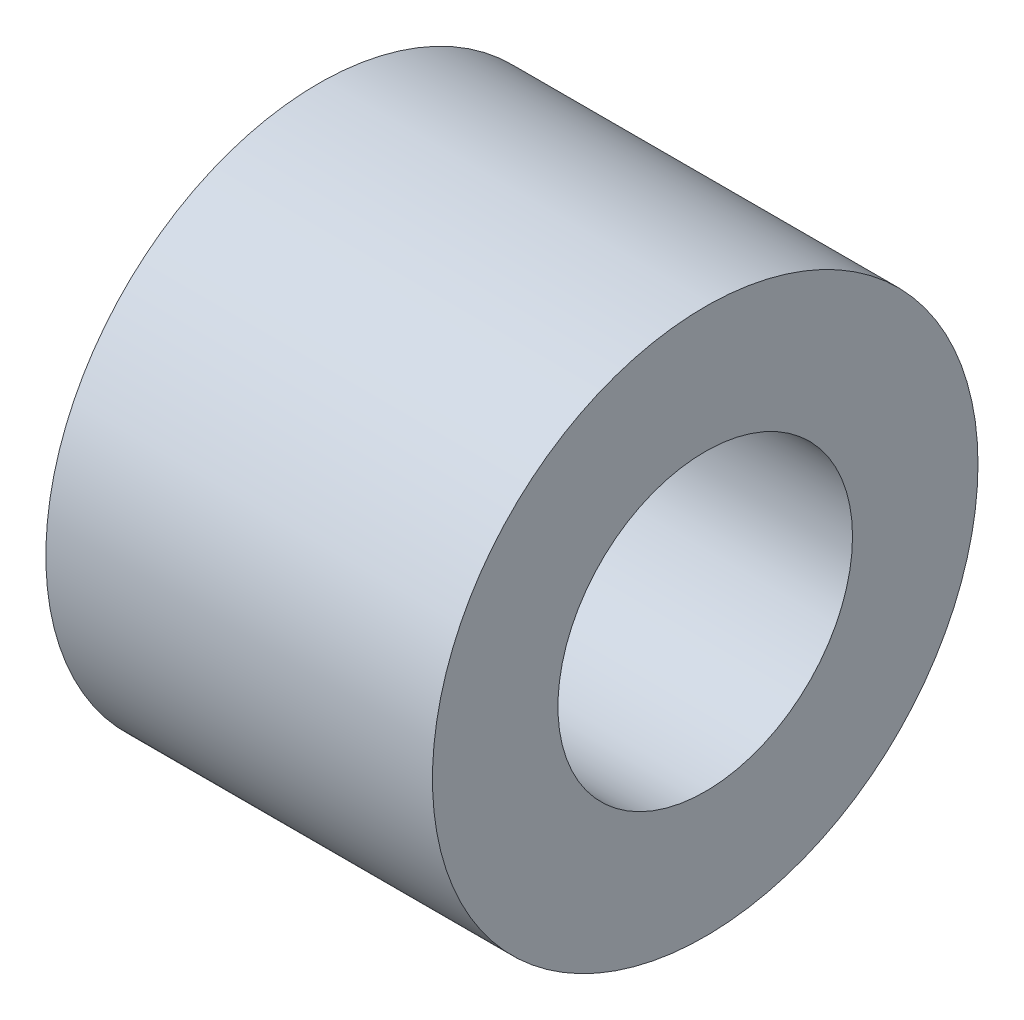
from build123d import *

# Parameters (mm, degrees)
ESQUISSE1_R        = 6.35
ESQUISSE1_R_2      = 3.429
BOSS_EXTRU_1_DEPTH = 9


with BuildPart() as part:
    # Esquisse1 → Boss.-Extru.1 (new body)
    with BuildSketch(Plane(origin=(0, 0, 0), x_dir=(0, 0, -1), z_dir=(1, 0, 0))):
        Circle(ESQUISSE1_R)
        Circle(ESQUISSE1_R_2, mode=Mode.SUBTRACT)
    extrude(amount=-BOSS_EXTRU_1_DEPTH)


solid = part.part
